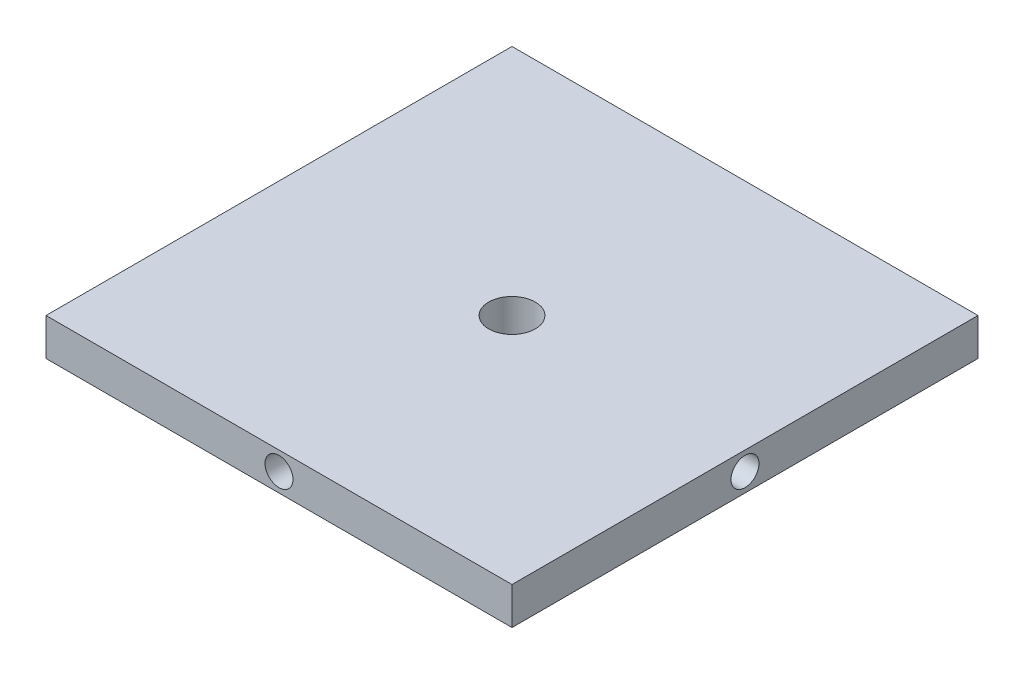
from build123d import *

# Parameters (mm, degrees)
SKETCH1_W                       = 317.5
SKETCH1_H                       = 317.5
SKETCH1_R                       = 15.875
BOSS_EXTRUDE1_DEPTH             = 25.4
F_3_4_0_75_DIAMETER_HOLE2_D     = 19.05
F_3_4_0_75_DIAMETER_HOLE2_DEPTH = 76.2
F_3_4_0_75_DIAMETER_HOLE2_TIP   = 5.723197396
F_3_4_0_75_DIAMETER_HOLE1_D     = 19.05
F_3_4_0_75_DIAMETER_HOLE1_DEPTH = 76.2
F_3_4_0_75_DIAMETER_HOLE1_TIP   = 5.723197396


with BuildPart() as part:
    # Sketch1 → Boss-Extrude1 (new body)
    with BuildSketch(Plane(origin=(0, 0, 0), x_dir=(1, 0, 0), z_dir=(0, 1, 0))):
        Rectangle(SKETCH1_W, SKETCH1_H)
        Circle(SKETCH1_R, mode=Mode.SUBTRACT)
    extrude(amount=BOSS_EXTRUDE1_DEPTH)

    # 3_4 _0.75_ Diameter Hole2
    with Locations(Plane(origin=(158.75, 0, 0), x_dir=(0, 0, -1), z_dir=(1, 0, 0))):
        with Locations((0, 12.7)):
            Hole(F_3_4_0_75_DIAMETER_HOLE2_D / 2, depth=F_3_4_0_75_DIAMETER_HOLE2_DEPTH)
            with Locations((0, 0, -(F_3_4_0_75_DIAMETER_HOLE2_DEPTH + F_3_4_0_75_DIAMETER_HOLE2_TIP / 2))):  # 118° drill point
                Cone(0, F_3_4_0_75_DIAMETER_HOLE2_D / 2, F_3_4_0_75_DIAMETER_HOLE2_TIP, mode=Mode.SUBTRACT)

    # 3_4 _0.75_ Diameter Hole1
    with Locations(Plane.XY.offset(158.75)):
        with Locations((0, 12.7)):
            Hole(F_3_4_0_75_DIAMETER_HOLE1_D / 2, depth=F_3_4_0_75_DIAMETER_HOLE1_DEPTH)
            with Locations((0, 0, -(F_3_4_0_75_DIAMETER_HOLE1_DEPTH + F_3_4_0_75_DIAMETER_HOLE1_TIP / 2))):  # 118° drill point
                Cone(0, F_3_4_0_75_DIAMETER_HOLE1_D / 2, F_3_4_0_75_DIAMETER_HOLE1_TIP, mode=Mode.SUBTRACT)


solid = part.part
